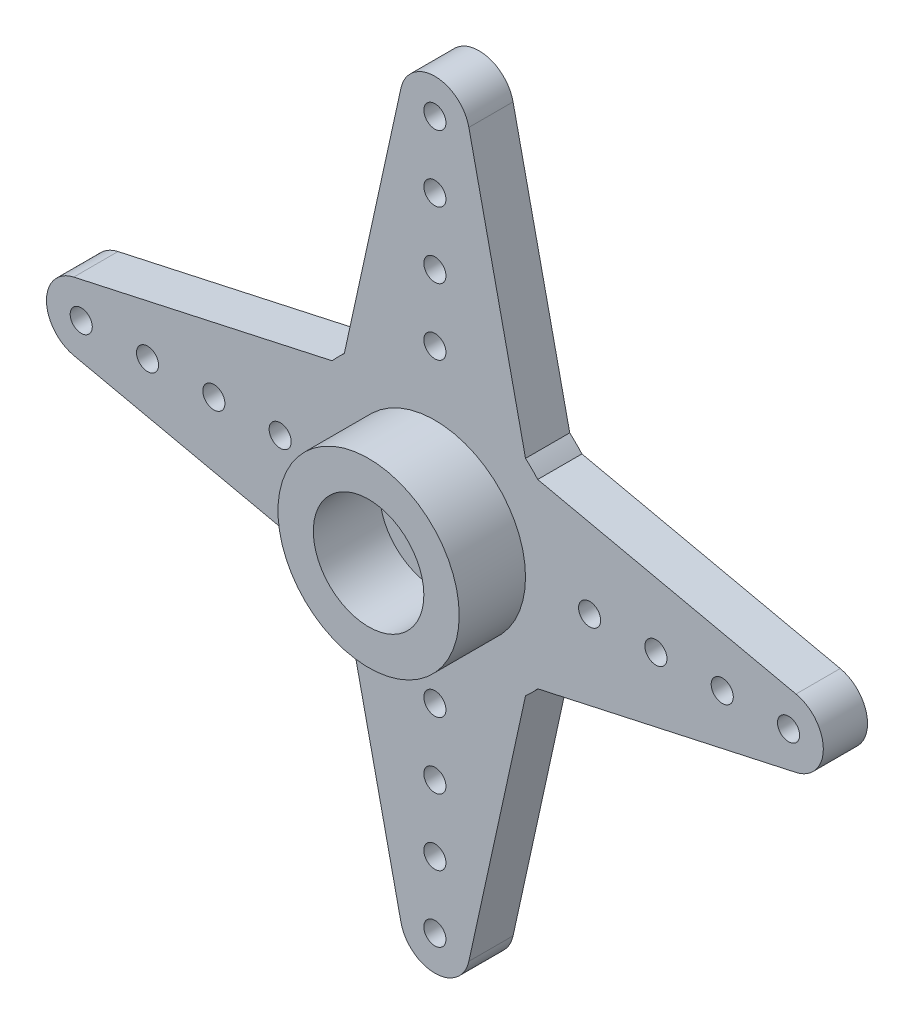
from build123d import *

# Parameters (mm, degrees)
ESQUISSE1_R                  = 1.5
ESQUISSE1_R_2                = 0.5
BOSS_EXTRU_1_DEPTH           = 2
ESQUISSE2_R                  = 4.1
ESQUISSE2_R_2                = 2.5
BOSS_EXTRU_2_DEPTH           = 3
R_P_TITION_CIRCULAIRE1_COUNT = 2
R_P_TITION_CIRCULAIRE1_ANGLE = 90


with BuildPart() as part:
    # Esquisse1 → Boss.-Extru.1 (new body)
    with BuildSketch(Plane.XY):
        with BuildLine():
            Line((-16.337044695, 1.536467752), (-4.650806382, 4.1))
            ThreePointArc((-4.650806382, 4.1), (0, 6.2), (4.650806382, 4.1))
            Line((4.650806382, 4.1), (16.337044695, 1.536467752))
            ThreePointArc((16.337044695, 1.536467752), (17.573001042, 0), (16.337044695, -1.536467752))
            Line((16.337044695, -1.536467752), (4.650806382, -4.1))
            ThreePointArc((4.650806382, -4.1), (0, -6.2), (-4.650806382, -4.1))
            Line((-4.650806382, -4.1), (-16.337044695, -1.536467752))
            ThreePointArc((-16.337044695, -1.536467752), (-17.573001042, 0), (-16.337044695, 1.536467752))
        make_face()
        Circle(ESQUISSE1_R, mode=Mode.SUBTRACT)
        with Locations((7, 0)):
            Circle(ESQUISSE1_R_2, mode=Mode.SUBTRACT)
        with Locations((16, 0)):
            Circle(ESQUISSE1_R_2, mode=Mode.SUBTRACT)
        with Locations((13, 0)):
            Circle(ESQUISSE1_R_2, mode=Mode.SUBTRACT)
        with Locations((10, 0)):
            Circle(ESQUISSE1_R_2, mode=Mode.SUBTRACT)
        with Locations((-16, 0)):
            Circle(ESQUISSE1_R_2, mode=Mode.SUBTRACT)
        with Locations((-13, 0)):
            Circle(ESQUISSE1_R_2, mode=Mode.SUBTRACT)
        with Locations((-10, 0)):
            Circle(ESQUISSE1_R_2, mode=Mode.SUBTRACT)
        with Locations((-7, 0)):
            Circle(ESQUISSE1_R_2, mode=Mode.SUBTRACT)
    boss_extru_1 = extrude(amount=BOSS_EXTRU_1_DEPTH)

    # Esquisse2 → Boss.-Extru.2 (add)
    with BuildSketch(Plane.XY.offset(2)):
        Circle(ESQUISSE2_R)
        Circle(ESQUISSE2_R_2, mode=Mode.SUBTRACT)
    extrude(amount=BOSS_EXTRU_2_DEPTH)

    # Répétition circulaire1: Boss.-Extru.1 ×2 about axis
    r_p_tition_circulaire1_axis = Axis((0, 0, -0.25), (0, 0, 1))
    for i in range(1, R_P_TITION_CIRCULAIRE1_COUNT):
        add(boss_extru_1.rotate(r_p_tition_circulaire1_axis, i * R_P_TITION_CIRCULAIRE1_ANGLE / (R_P_TITION_CIRCULAIRE1_COUNT - 1)))


solid = part.part
